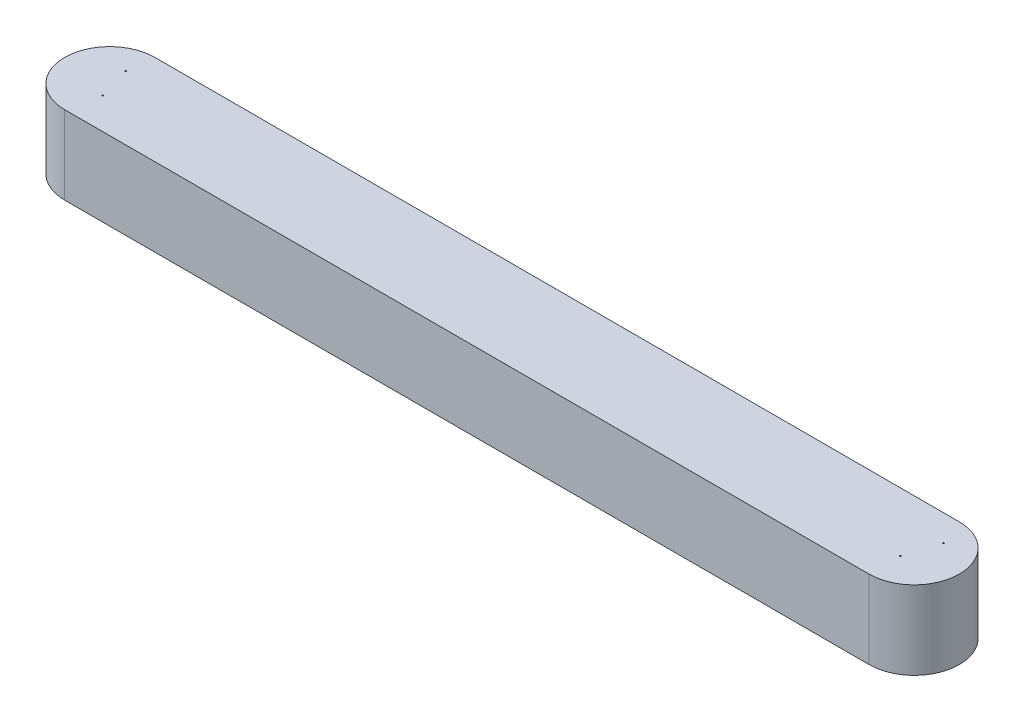
from build123d import *

# Parameters (mm, degrees)
BOSS_EXTRUDE1_DEPTH   = 74.341091188
F_0_80_TAPPED_HOLE2_D = 1.19126


with BuildPart() as part:
    # Sketch1 → Boss-Extrude1 (new body)
    with BuildSketch(Plane(origin=(0, 0, 0), x_dir=(1, 0, 0), z_dir=(0, 1, 0))):
        with BuildLine():
            Line((0, -42.854004512), (-763.0290048, -42.854004512))
            ThreePointArc((-763.0290048, -42.854004512), (-805.883009312, 0), (-763.0290048, 42.854004512))
            Line((-763.0290048, 42.854004512), (0, 42.854004512))
            ThreePointArc((0, 42.854004512), (42.854004512, 0), (0, -42.854004512))
        make_face()
    extrude(amount=BOSS_EXTRUDE1_DEPTH)

    # #0-80 Tapped Hole2 (through all)
    with Locations(Plane(origin=(0, 74.341091188, 0), x_dir=(1, 0, 0), z_dir=(0, 1, 0))):
        with Locations((9.862991623, 17.879805094), (0, -13.073814135), (-765.853466012, 17.879805094), (-756.473581397, -13.073814135)):
            Hole(F_0_80_TAPPED_HOLE2_D / 2)


solid = part.part
